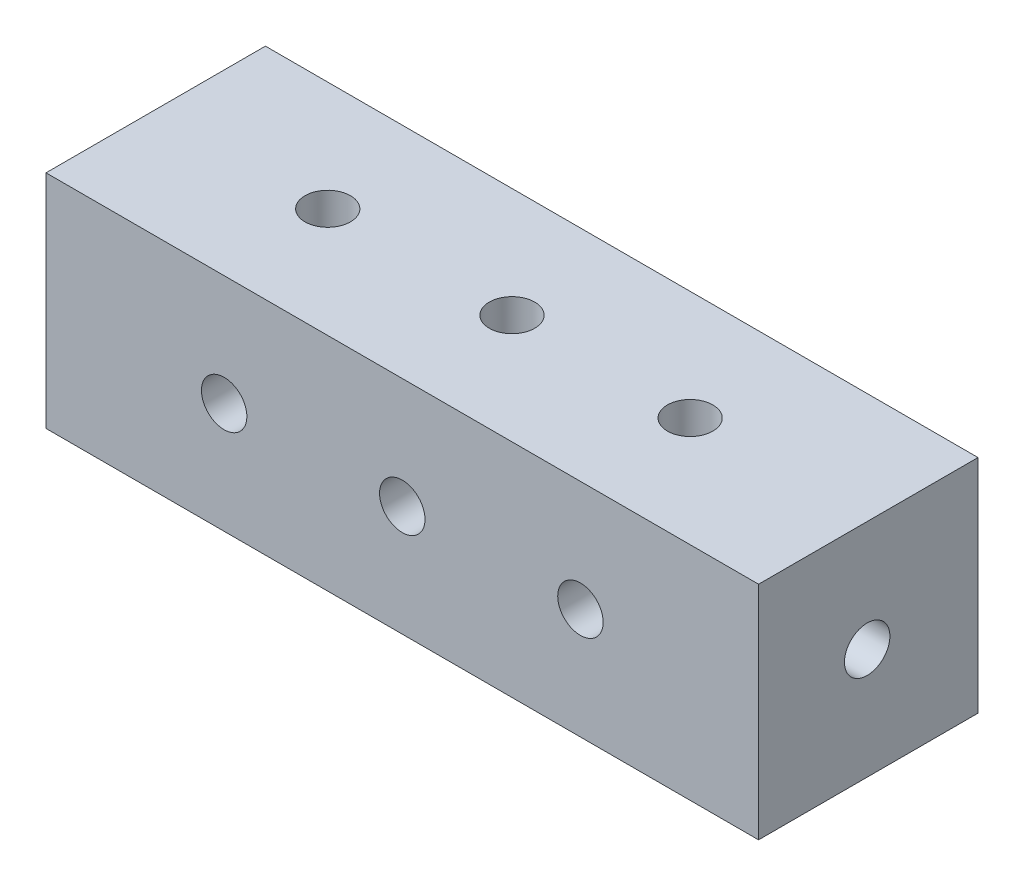
from build123d import *

# Parameters (mm, degrees)
ESBO_O1_W                  = 128.6
ESBO_O1_H                  = 39.96
RESSALTO_EXTRUS_O1_DEPTH   = 39.6
ESBO_O2_R                  = 4.1
CORTE_EXTRUS_O1_DEPTH      = 49
CORTE_EXTRUS_O1_DEPTH_BACK = 9
ESBO_O3_R                  = 4.1
CORTE_EXTRUS_O2_DEPTH      = 157
CORTE_EXTRUS_O2_DEPTH_BACK = 19
ESBO_O4_R                  = 4.1
CORTE_EXTRUS_O3_DEPTH      = 64
CORTE_EXTRUS_O3_DEPTH_BACK = 26


with BuildPart() as part:
    # Esboço1 → Ressalto-extrusão1 (new body)
    with BuildSketch(Plane.XY):
        with Locations((64.3, 19.98)):
            Rectangle(ESBO_O1_W, ESBO_O1_H)
    extrude(amount=RESSALTO_EXTRUS_O1_DEPTH)

    # Esboço2 → Corte-extrusão1 (cut, two sides)
    with BuildSketch(Plane(origin=(0, 0, 0), x_dir=(1, 0, 0), z_dir=(0, 1, 0))) as corte_extrus_o1_sk:
        with Locations((31.044518882, -19.8)):
            Circle(ESBO_O2_R)
        with Locations((96.45, -19.8)):
            Circle(ESBO_O2_R)
        with Locations((64.3, -19.8)):
            Circle(ESBO_O2_R)
    extrude(amount=CORTE_EXTRUS_O1_DEPTH, mode=Mode.SUBTRACT)
    extrude(corte_extrus_o1_sk.sketch, amount=-CORTE_EXTRUS_O1_DEPTH_BACK, mode=Mode.SUBTRACT)

    # Esboço3 → Corte-extrusão2 (cut, two sides)
    with BuildSketch(Plane(origin=(0, 0, 0), x_dir=(0, 0, -1), z_dir=(1, 0, 0))) as corte_extrus_o2_sk:
        with Locations((-20, 20)):
            Circle(ESBO_O3_R)
    extrude(amount=CORTE_EXTRUS_O2_DEPTH, mode=Mode.SUBTRACT)
    extrude(corte_extrus_o2_sk.sketch, amount=-CORTE_EXTRUS_O2_DEPTH_BACK, mode=Mode.SUBTRACT)

    # Esboço4 → Corte-extrusão3 (cut, two sides)
    with BuildSketch(Plane.XY) as corte_extrus_o3_sk:
        with Locations((32.15, 19.98)):
            Circle(ESBO_O4_R)
        with Locations((64.3, 19.98)):
            Circle(ESBO_O4_R)
        with Locations((96.45, 19.98)):
            Circle(ESBO_O4_R)
    extrude(amount=CORTE_EXTRUS_O3_DEPTH, mode=Mode.SUBTRACT)
    extrude(corte_extrus_o3_sk.sketch, amount=-CORTE_EXTRUS_O3_DEPTH_BACK, mode=Mode.SUBTRACT)


solid = part.part
